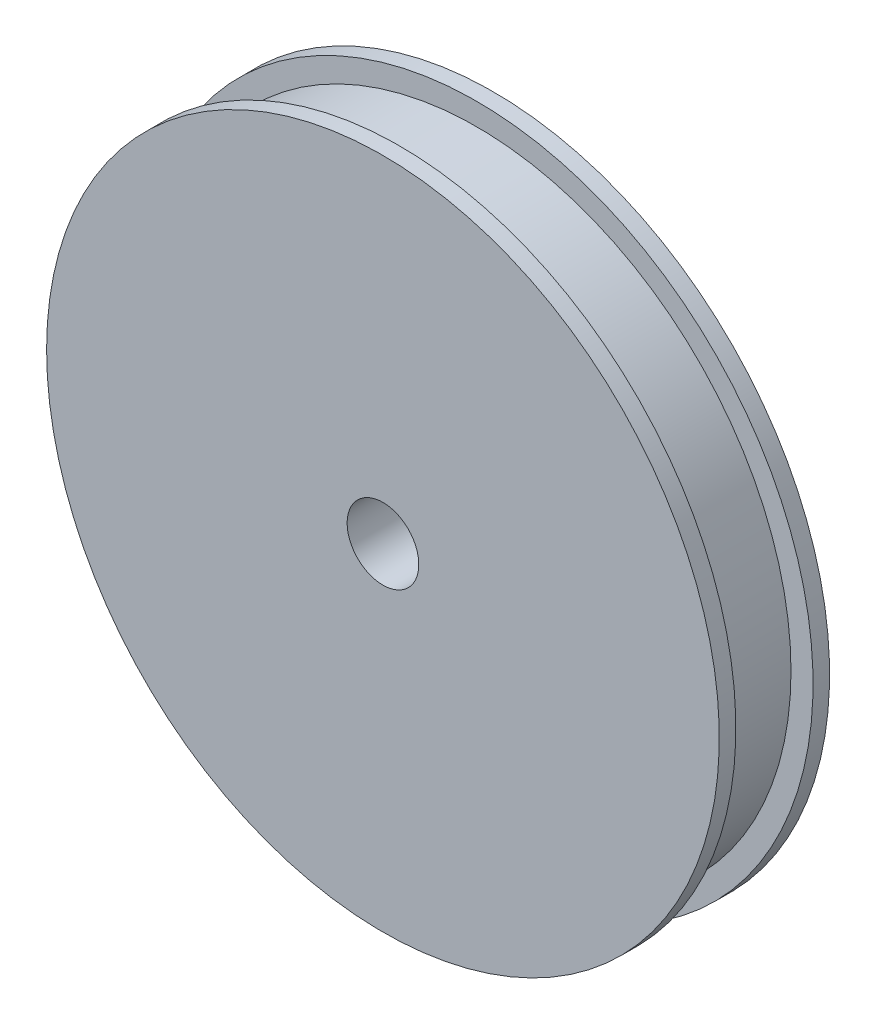
from build123d import *

# Parameters (mm, degrees)
SKETCH_3_R          = 15
EXTRUDE_1_DEPTH     = 7
SKETCH_4_R          = 3.25
CUT_EXTRUDE_1_DEPTH = 18


with BuildPart() as part:
    # Эскиз2 → Повернуть1 (revolve)
    with BuildSketch(Plane(origin=(0, 0, 0), x_dir=(0, 0, -1), z_dir=(1, 0, 0))):
        Polygon((0, 0), (0, 30.5), (1.5, 30.5), (1.5, 28.5), (8.5, 28.5), (8.5, 30.5), (10, 30.5), (10, 0), align=None)
    revolve(axis=Axis((0, 0, -10), (0, 0, 1)))

    # Эскиз3 → Бобышка-Вытянуть1 (add)
    with BuildSketch(Plane(origin=(0, 0, -10), x_dir=(-1, 0, 0), z_dir=(0, 0, -1))):
        Circle(SKETCH_3_R)
    extrude(amount=EXTRUDE_1_DEPTH)

    # Эскиз4 → Вырез-Вытянуть1 (cut, through all)
    with BuildSketch(Plane(origin=(0, 0, -17), x_dir=(-1, 0, 0), z_dir=(0, 0, -1))):
        Circle(SKETCH_4_R)
    extrude(amount=-CUT_EXTRUDE_1_DEPTH, mode=Mode.SUBTRACT)


solid = part.part
